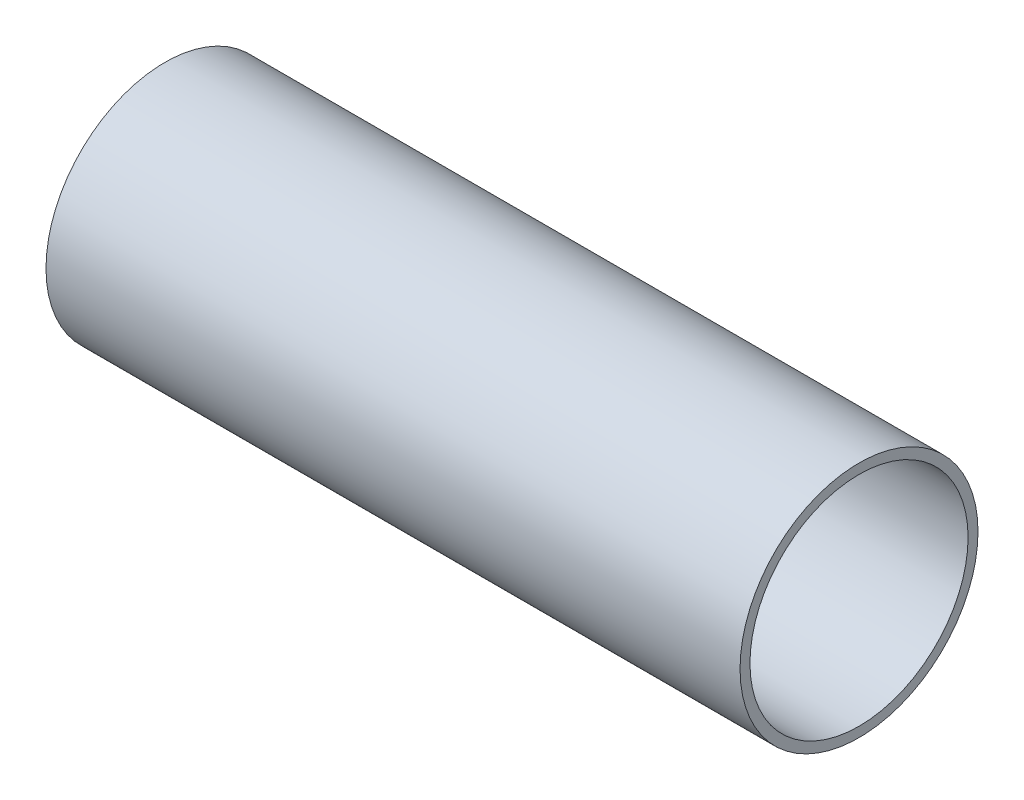
from build123d import *

# Parameters (mm, degrees)
SKETCH_1_R      = 60
SKETCH_1_R_2    = 55
EXTRUDE_1_DEPTH = 350


with BuildPart() as part:
    # Эскиз1 → Бобышка-Вытянуть1 (new body)
    with BuildSketch(Plane(origin=(0, 0, 0), x_dir=(0, 0, -1), z_dir=(1, 0, 0))):
        Circle(SKETCH_1_R)
        Circle(SKETCH_1_R_2, mode=Mode.SUBTRACT)
    extrude(amount=EXTRUDE_1_DEPTH)


solid = part.part
